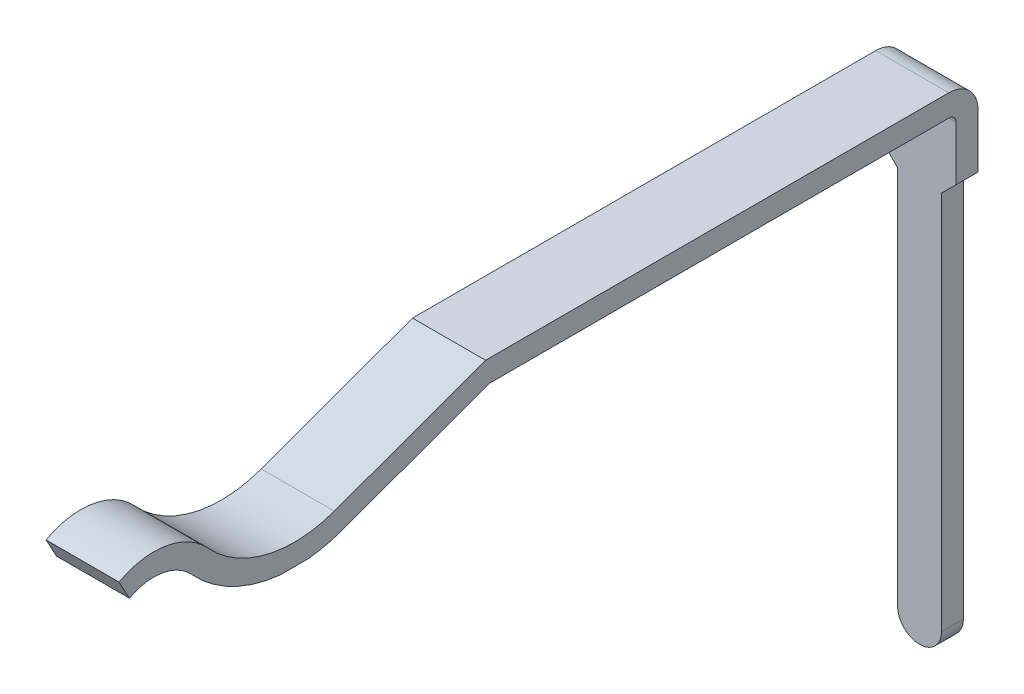
from build123d import *

# Parameters (mm, degrees)
EXTRUDE_THIN1_DEPTH = 0.5
CUT_EXTRUDE1_DEPTH  = 13.76


with BuildPart() as part:
    # Sketch1 → Extrude-Thin1 (new body, symmetric)
    with BuildSketch(Plane(origin=(0, 0, 0), x_dir=(0, 0, -1), z_dir=(1, 0, 0))):
        with BuildLine():
            ThreePointArc((1, -0.121157255), (1.643863846, -0.014001181), (2.216684029, -0.326923077))
            ThreePointArc((2.216684029, -0.326923077), (3.017058298, -0.803497877), (3.947232229, -0.753508193))
            Line((3.947232229, -0.753508193), (6.017478976, 0))
            Line((6.017478976, 0), (12.36, 0))
            ThreePointArc((12.36, 0), (12.642842712, -0.117157288), (12.76, -0.4))
            Line((12.76, -0.4), (12.76, -6.84))
            Line((12.76, -6.84), (12.46, -6.84))
            Line((12.46, -6.84), (12.46, -0.4))
            ThreePointArc((12.46, -0.4), (12.430710678, -0.329289322), (12.36, -0.3))
            Line((12.36, -0.3), (6.07037707, -0.3))
            Line((6.07037707, -0.3), (4.049838272, -1.035415979))
            ThreePointArc((4.049838272, -1.035415979), (2.945256729, -1.094778729), (1.994812285, -0.528846154))
            ThreePointArc((1.994812285, -0.528846154), (1.593838156, -0.309800827), (1.143133464, -0.384810078))
            Line((1.143133464, -0.384810078), (1, -0.121157255))
        make_face()
    extrude(amount=EXTRUDE_THIN1_DEPTH, both=True)

    # Sketch2 → Cut-Extrude1 (cut, through all)
    with BuildSketch(Plane.XY):
        with BuildLine():
            Line((-0.3, -6.54), (-0.3, -1.34))
            Line((-0.3, -1.34), (-0.5, -1.14))
            Line((-0.5, -1.14), (-0.5, -7.54))
            Line((-0.5, -7.54), (0.5, -7.54))
            Line((0.5, -7.54), (0.5, -1.14))
            Line((0.5, -1.14), (0.3, -1.34))
            Line((0.3, -1.34), (0.3, -6.54))
            ThreePointArc((0.3, -6.54), (0, -6.84), (-0.3, -6.54))
        make_face()
    extrude(amount=-CUT_EXTRUDE1_DEPTH, mode=Mode.SUBTRACT)


solid = part.part
